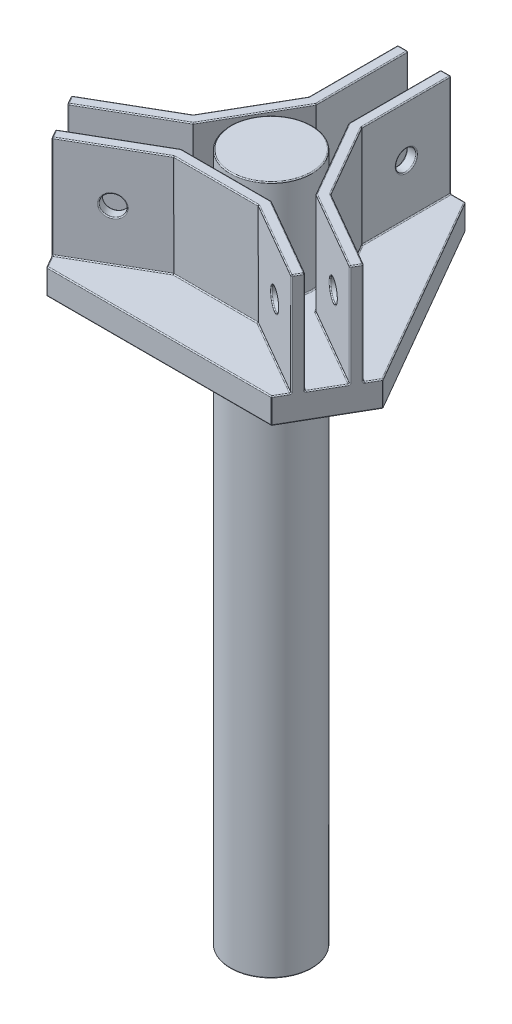
from build123d import *

# Parameters (mm, degrees)
BOSS_EXTRUDE1_DEPTH = 2.5
SKETCH2_R           = 4
BOSS_EXTRUDE2_DEPTH = 10
BOSS_EXTRUDE3_START = 55
SKETCH3_R           = 4
BOSS_EXTRUDE3_DEPTH = 55
SKETCH4_R           = 1.0000000000000013
CUT_EXTRUDE1_DEPTH  = 60.66595641619599
CIRPATTERN1_COUNT   = 3
FILLET1_R           = 0.1


with BuildPart() as part:
    # Sketch1 → Boss-Extrude1 (new body)
    with BuildSketch(Plane(origin=(0, 0, 0), x_dir=(1, 0, 0), z_dir=(0, 1, 0))):
        Polygon((-4, 15.009999999999998), (4, 15.01), (14.999041310804405, -4.040898384862316), (10.999041310804373, -10.969101615137808), (-10.999041310804365, -10.969101615137808), (-14.999041310804403, -4.0408983848623174), align=None)
    extrude(amount=BOSS_EXTRUDE1_DEPTH)

    # Sketch2 → Boss-Extrude2 (add)
    with BuildSketch(Plane(origin=(0, 2.5, 0), x_dir=(1, 0, 0), z_dir=(0, 1, 0))):
        with Locations(Location((0, 0, 0), (0, 0, 90))):
            Circle(SKETCH2_R)
        Polygon((-12.199041310804377, -8.89064064605516), (-4.404812676744452, -4.390640646055122), (4.404812676744452, -4.390640646055122), (12.199041310804386, -8.890640646055163), (11.699041310804382, -9.7566660498396), (4.136863484313325, -5.390640646055122), (-4.136863484313331, -5.390640646055122), (-11.699041310804374, -9.756666049839597), align=None)
        Polygon((-2.600000000000003, 15.01), (-2.5999999999999983, 6.2779491924311275), (-6.736863484313361, -0.8873085463759547), (-14.29904131080448, -5.253333950160328), (-13.799041310804487, -6.1193593539447715), (-6.004812676744488, -1.6193593539448385), (-1.6000000000000003, 6.009999999999999), (-1.6000000000000034, 15.01), align=None)
        Polygon((14.299041310804398, -5.2533339501605205), (6.736863484313352, -0.8873085463760536), (2.6000000000000902, 6.277949192431085), (2.6000000000002124, 15.00999999999997), (1.6000000000002106, 15.009999999999982), (1.6000000000000854, 6.009999999999975), (6.004812676744466, -1.6193593539449227), (13.799041310804395, -6.119359353944956), align=None)
    extrude(amount=BOSS_EXTRUDE2_DEPTH)

    # Sketch3 → Boss-Extrude3 (add)
    with BuildSketch(Plane.XZ.offset(BOSS_EXTRUDE3_START)):
        with Locations(Location((0, 0, 0), (0, 0, 270))):
            Circle(SKETCH3_R)
    extrude(amount=-BOSS_EXTRUDE3_DEPTH)

    # Sketch4 → Cut-Extrude1 (cut, symmetric)
    with BuildSketch(Plane.ZY.offset(2.5999999999999943)):
        with Locations((-10.643974596215564, 7.500000000000001)):
            Circle(SKETCH4_R)
    cut_extrude1 = extrude(amount=CUT_EXTRUDE1_DEPTH, both=True, mode=Mode.SUBTRACT)

    # CirPattern1: Cut-Extrude1 ×3 about axis
    cirpattern1_axis = Axis((0, 12.5, 0), (0, -1, 0))
    for i in range(1, CIRPATTERN1_COUNT):
        add(cut_extrude1.rotate(cirpattern1_axis, i * 360 / CIRPATTERN1_COUNT), mode=Mode.SUBTRACT)

    # Fillet1
    fillet1_edges = [part.edges().sort_by_distance(p)[0] for p in [
        (-9.4995206554022, 2.5, -5.48455080756884),
        (14.999041310804405, 1.25, 4.040898384862316),
        (10.999041310804373, 1.25, 10.969101615137808),
        (-10.999041310804365, 1.25, 10.969101615137808),
        (-14.999041310804403, 1.25, 4.0408983848623174),
        (-4, 1.25, -15.009999999999998),
        (-9.283977801343303, 7.500000000000001, 7.2076279441629305),
        (-8.783977801343301, 7.500000000000001, 8.073653347947367),
        (-10.883977801343383, 7.500000000000001, 4.4363466520525945),
        (-11.383977801343384, 7.500000000000001, 3.570321248268156),
        (4, 1.25, -15.01),
        (9.283977801343305, 7.500000000000001, 7.207627944162928),
        (8.783977801343305, 7.500000000000001, 8.073653347947369),
        (10.883977801343306, 7.500000000000001, 4.43634665205272),
        (11.383977801343306, 7.500000000000001, 3.5703212482682813),
        (-14.649041310804453, 2.5, 4.64711616751133),
        (3.55e-15, 2.5, 10.969101615137808),
        (-7.3e-16, 2.5, 4),
        (11.349041310804374, 2.5, 10.362883832488702),
        (-7.3e-16, 12.5, 4),
        (-11.349041310804369, 2.5, 10.362883832488702),
        (12.99904131080439, 2.5, 7.50500000000006),
        (-12.199041310804377, 7.5, 8.89064064605516),
        (-7.917952397558852, 2.5, 7.573653347947359),
        (-11.699041310804374, 7.5, 9.756666049839597),
        (-2.66e-15, 2.5, 5.390640646055122),
        (-4.136863484313331, 7.5, 5.390640646055122),
        (7.917952397558854, 2.5, 7.573653347947361),
        (4.136863484313325, 7.5, 5.390640646055122),
        (11.699041310804382, 7.5, 9.7566660498396),
        (8.30192699377442, 2.5, 6.640640646055142),
        (12.199041310804386, 7.5, 8.890640646055163),
        (0, 2.5, 4.390640646055122),
        (4.404812676744452, 7.5, 4.390640646055122),
        (-8.301926993774416, 2.5, 6.640640646055141),
        (-4.404812676744452, 7.5, 4.390640646055122),
        (-11.949041310804375, 12.5, 9.323653347947378),
        (-7.917952397558852, 12.5, 7.573653347947359),
        (-2.66e-15, 12.5, 5.390640646055122),
        (7.917952397558854, 12.5, 7.573653347947361),
        (11.949041310804384, 12.5, 9.323653347947381),
        (8.30192699377442, 12.5, 6.640640646055142),
        (0, 12.5, 4.390640646055122),
        (-8.301926993774416, 12.5, 6.640640646055141),
        (9.499520655402202, 2.5, -5.4845508075688425),
        (-12.999041310804438, 2.5, 7.50499999999997),
        (-3.3000000000000016, 2.5, -15.009999999999998),
        (-1.6000000000000034, 7.5, -15.01),
        (-2.6000000000000005, 2.5, -10.643974596215564),
        (-2.600000000000003, 7.5, -15.01),
        (-4.668431742156679, 2.5, -2.695320323027586),
        (-2.5999999999999983, 7.5, -6.2779491924311275),
        (-10.51795239755892, 2.5, 3.0703212482681415),
        (-6.736863484313361, 7.5, 0.8873085463759547),
        (-14.29904131080448, 7.5, 5.253333950160328),
        (-9.901926993774488, 2.5, 3.8693593539448052),
        (-13.799041310804487, 7.5, 6.1193593539447715),
        (-3.8024063383722444, 2.5, -2.19532032302758),
        (-6.004812676744488, 7.5, 1.6193593539448385),
        (-1.6000000000000019, 2.5, -10.509999999999998),
        (-1.6000000000000003, 7.5, -6.009999999999999),
        (-2.100000000000003, 12.5, -15.01),
        (-2.6000000000000005, 12.5, -10.643974596215564),
        (-4.668431742156679, 12.5, -2.695320323027586),
        (-10.51795239755892, 12.5, 3.0703212482681415),
        (-14.049041310804483, 12.5, 5.686346652052549),
        (-9.901926993774488, 12.5, 3.8693593539448052),
        (-3.8024063383722444, 12.5, -2.19532032302758),
        (-1.6000000000000019, 12.5, -10.509999999999998),
        (12.999041310804389, 0, 7.505000000000061),
        (14.649041310804403, 2.5, 4.647116167511419),
        (1.0392e-13, 2.5, -15.01),
        (3.55e-15, 0, 10.969101615137808),
        (13.799041310804395, 7.5, 6.119359353944956),
        (10.517952397558876, 2.5, 3.070321248268287),
        (14.299041310804398, 7.5, 5.2533339501605205),
        (4.668431742156721, 2.5, -2.6953203230275156),
        (6.736863484313352, 7.5, 0.8873085463760536),
        (2.6000000000001515, 2.5, -10.643974596215529),
        (2.6000000000000902, 7.5, -6.277949192431085),
        (2.6000000000002124, 7.5, -15.00999999999997),
        (1.600000000000148, 2.5, -10.509999999999978),
        (-12.999041310804383, 0, 7.505000000000063),
        (1.6000000000002106, 7.5, -15.009999999999982),
        (3.802406338372276, 2.5, -2.195320323027526),
        (1.6000000000000854, 7.5, -6.009999999999975),
        (9.901926993774431, 2.5, 3.8693593539449394),
        (6.004812676744466, 7.5, 1.6193593539449227),
        (3.3000000000001064, 2.5, -15.01),
        (14.049041310804396, 12.5, 5.686346652052738),
        (10.517952397558876, 12.5, 3.070321248268287),
        (4.668431742156721, 12.5, -2.6953203230275156),
        (2.6000000000001515, 12.5, -10.643974596215529),
        (2.1000000000002115, 12.5, -15.009999999999977),
        (1.600000000000148, 12.5, -10.509999999999978),
        (3.802406338372276, 12.5, -2.195320323027526),
        (9.901926993774431, 12.5, 3.8693593539449394),
        (-9.4995206554022, 0, -5.48455080756884),
        (0, 0, -15.009999999999998),
        (9.499520655402202, 0, -5.4845508075688425),
        (1.22e-15, 0, 4),
        (1.22e-15, -55, 4),
        (-1.6000000000000025, 7.500000000000001, -11.643974596215564),
        (-2.600000000000001, 7.500000000000001, -11.643974596215564),
        (1.600000000000149, 7.500000000000001, -11.643974596215566),
        (2.600000000000151, 7.500000000000001, -11.643974596215568),
    ]]
    fillet(fillet1_edges, radius=FILLET1_R)


solid = part.part
